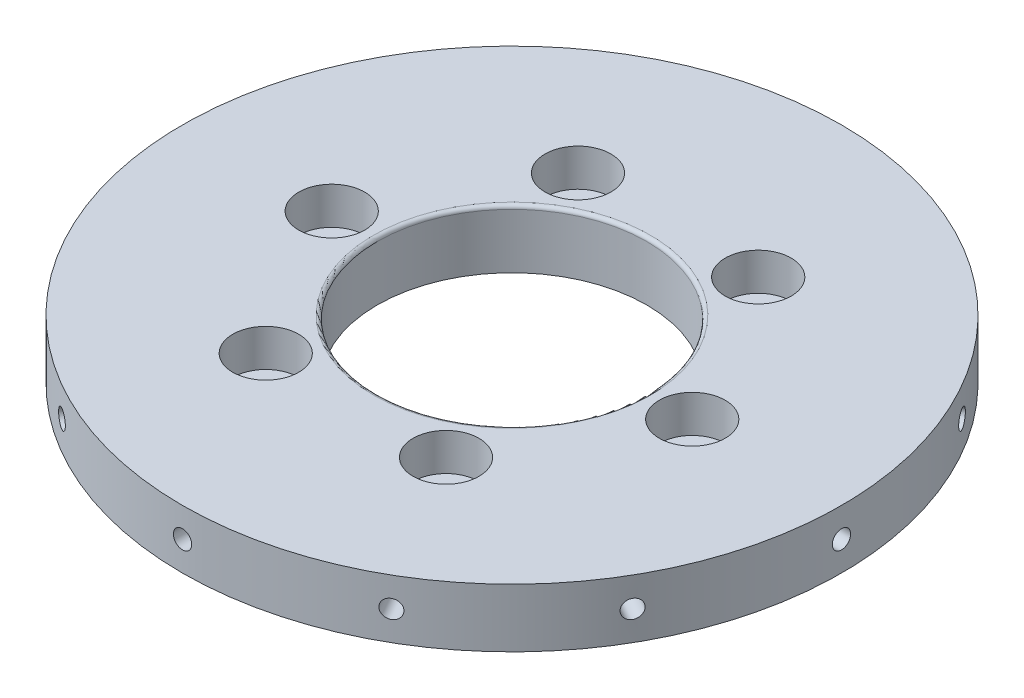
from build123d import *

# Parameters (mm, degrees)
SKETCH_1_R               = 44.975
SKETCH_1_R_2             = 2.1
SKETCH_1_R_3             = 18.4
EXTRUDE_1_DEPTH          = 8
SKETCH_2_R               = 4
CUT_EXTRUDE_1_DEPTH      = 3
SKETCH_4_R               = 4.5
CUT_EXTRUDE_2_DEPTH      = 5.1
SKETCH_5_R               = 1.25
CUT_EXTRUDE_3_DEPTH      = 10
PATTERN_CIRCULAR_1_COUNT = 12
FILLET_1_R               = 0.5


with BuildPart() as part:
    # 草图1 → 凸台-拉伸1 (new body)
    with BuildSketch(Plane(origin=(0, 0, 0), x_dir=(1, 0, 0), z_dir=(0, 1, 0))):
        Circle(SKETCH_1_R)
        with Locations((-24.6, 0)):
            Circle(SKETCH_1_R_2, mode=Mode.SUBTRACT)
        with Locations((-12.3, 21.304224933)):
            Circle(SKETCH_1_R_2, mode=Mode.SUBTRACT)
        with Locations((12.3, 21.304224933)):
            Circle(SKETCH_1_R_2, mode=Mode.SUBTRACT)
        with Locations((24.6, 0)):
            Circle(SKETCH_1_R_2, mode=Mode.SUBTRACT)
        with Locations((12.3, -21.304224933)):
            Circle(SKETCH_1_R_2, mode=Mode.SUBTRACT)
        with Locations((-12.3, -21.304224933)):
            Circle(SKETCH_1_R_2, mode=Mode.SUBTRACT)
        Circle(SKETCH_1_R_3, mode=Mode.SUBTRACT)
    extrude(amount=EXTRUDE_1_DEPTH)

    # 草图2 → 切除-拉伸1 (cut)
    with BuildSketch(Plane.XZ):
        with Locations((-21.304224933, -12.3)):
            Circle(SKETCH_2_R)
        with Locations((0, 24.6)):
            Circle(SKETCH_2_R)
        with Locations((21.304224933, -12.3)):
            Circle(SKETCH_2_R)
    extrude(amount=-CUT_EXTRUDE_1_DEPTH, mode=Mode.SUBTRACT)

    # 草图4 → 切除-拉伸2 (cut)
    with BuildSketch(Plane(origin=(0, 8, 0), x_dir=(1, 0, 0), z_dir=(0, 1, 0))):
        with Locations((-24.6, 0)):
            Circle(SKETCH_4_R)
        with Locations((-12.3, 21.304224933)):
            Circle(SKETCH_4_R)
        with Locations((12.3, 21.304224933)):
            Circle(SKETCH_4_R)
        with Locations((24.6, 0)):
            Circle(SKETCH_4_R)
        with Locations((12.3, -21.304224933)):
            Circle(SKETCH_4_R)
        with Locations((-12.3, -21.304224933)):
            Circle(SKETCH_4_R)
    extrude(amount=-CUT_EXTRUDE_2_DEPTH, mode=Mode.SUBTRACT)

    # 草图5 → 切除-拉伸3 (cut)
    with BuildSketch(Plane(origin=(45, 0, 0), x_dir=(0, 0, -1), z_dir=(1, 0, 0))):
        with Locations((0, 4)):
            Circle(SKETCH_5_R)
    cut_extrude_3 = extrude(amount=-CUT_EXTRUDE_3_DEPTH, mode=Mode.SUBTRACT)

    # 阵列(圆周)1: 切除-拉伸3 ×12 about axis
    pattern_circular_1_axis = Axis((0, 0, 0), (0, 1, 0))
    for i in range(1, PATTERN_CIRCULAR_1_COUNT):
        add(cut_extrude_3.rotate(pattern_circular_1_axis, i * 360 / PATTERN_CIRCULAR_1_COUNT), mode=Mode.SUBTRACT)

    # 圆角1
    fillet_1_edges = [part.edges().sort_by_distance(p)[0] for p in [
        (-18.4, 8, 0),
    ]]
    fillet(fillet_1_edges, radius=FILLET_1_R)


solid = part.part
